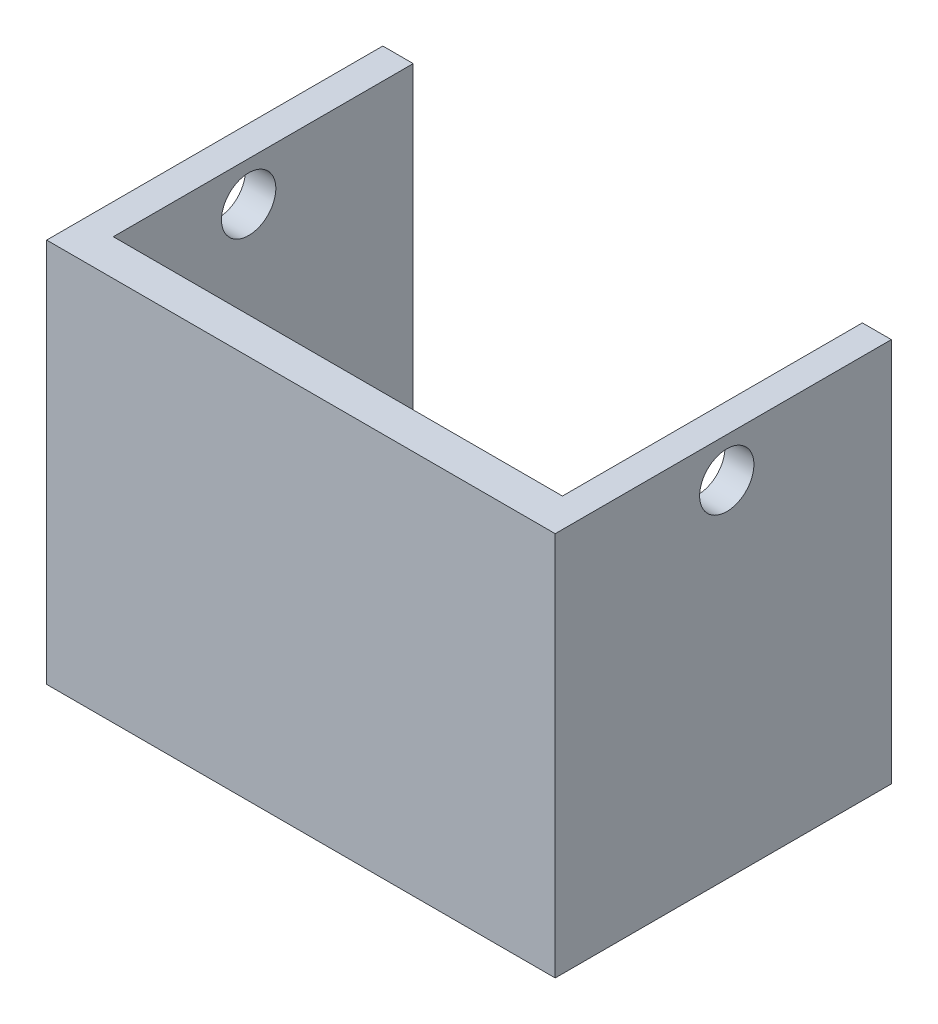
from build123d import *

# Parameters (mm, degrees)
SALIENTE_EXTRUIR2_DEPTH = 60
CROQUIS4_R              = 4.23503961
CORTAR_EXTRUIR1_DEPTH   = 110


with BuildPart() as part:
    # Croquis3 → Saliente-Extruir2 (new body)
    with BuildSketch(Plane(origin=(0, 0, 0), x_dir=(1, 0, 0), z_dir=(0, 1, 0))):
        Polygon((-33.38838539, 0), (-33.38838539, 39.424440528), (-28.644268776, 39.424440528), (-28.644268776, 0), (-28.644268776, -7.338994669), (41.387928863, -7.338994669), (41.387928863, 39.424440528), (45.906135162, 39.424440528), (45.906135162, -12.986752543), (-33.38838539, -12.986752543), align=None)
    extrude(amount=SALIENTE_EXTRUIR2_DEPTH)

    # Croquis4 → Cortar-Extruir1 (cut)
    with BuildSketch(Plane.ZY.offset(33.38838539)):
        with Locations((-13.763852604, 53.844361948)):
            Circle(CROQUIS4_R)
    extrude(amount=-CORTAR_EXTRUIR1_DEPTH, mode=Mode.SUBTRACT)


solid = part.part
